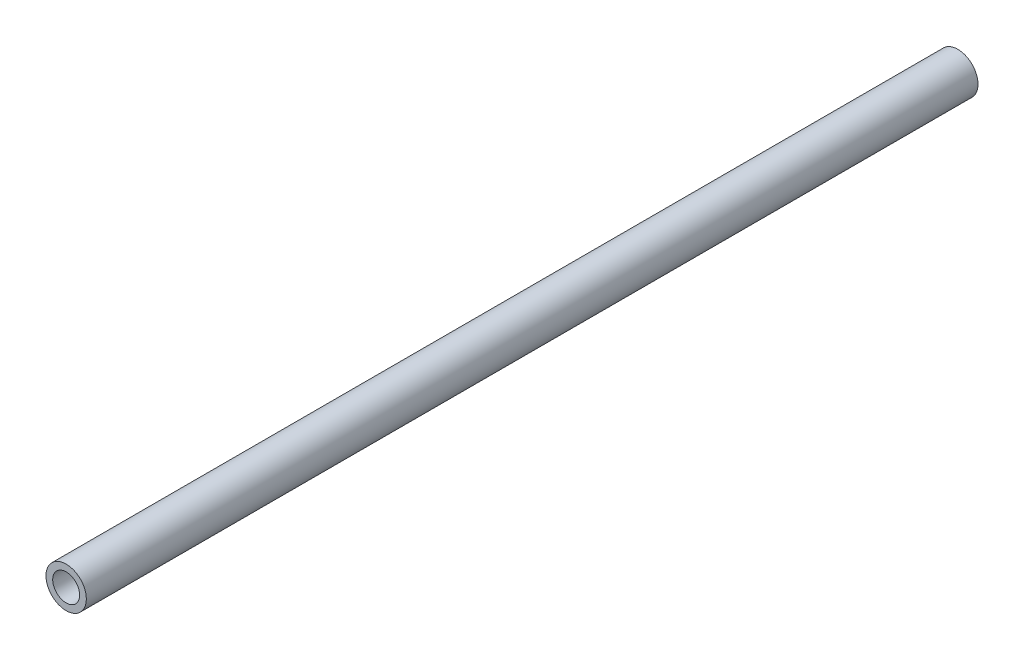
from build123d import *

# Parameters (mm, degrees)
SKETCH1_R           = 7.62
SKETCH1_R_2         = 5.08
BOSS_EXTRUDE1_DEPTH = 336.55


with BuildPart() as part:
    # Sketch1 → Boss-Extrude1 (new body)
    with BuildSketch(Plane.XY):
        Circle(SKETCH1_R)
        Circle(SKETCH1_R_2, mode=Mode.SUBTRACT)
    extrude(amount=BOSS_EXTRUDE1_DEPTH)


solid = part.part
